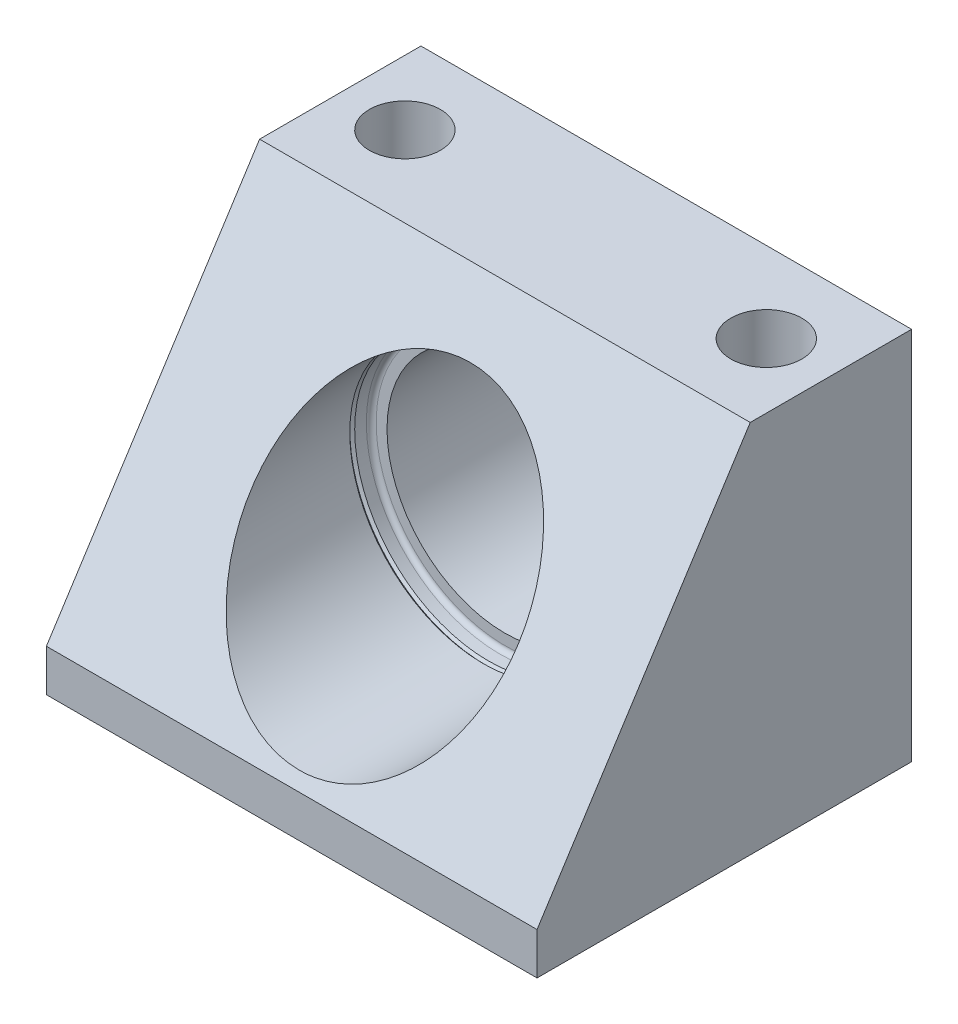
from build123d import *

# Parameters (mm, degrees)
SKETCH1_W          = 75.9968
SKETCH1_H          = 58.0136
SKETCH1_R          = 18.2625
EXTRUDE1_DEPTH     = 58.0136
CUT_EXTRUDE1_DEPTH = 76.9968
SKETCH3_R          = 20.701
CUT_EXTRUDE2_DEPTH = 33.02
FILLET1_R          = 0.762
HOLE1_D            = 10.9982
HOLE1_DEPTH        = 58.0136


with BuildPart() as part:
    # Sketch1 → Extrude1 (new body)
    with BuildSketch(Plane.XY):
        with Locations((37.9984, 29.0068)):
            Rectangle(SKETCH1_W, SKETCH1_H)
        with Locations((37.9984, 29.0068)):
            Circle(SKETCH1_R, mode=Mode.SUBTRACT)
    extrude(amount=-EXTRUDE1_DEPTH)

    # Sketch2 → Cut-Extrude1 (cut, through all)
    with BuildSketch(Plane(origin=(75.9968, 0, 0), x_dir=(0, 0, -1), z_dir=(1, 0, 0))):
        Polygon((0, 58.0136), (33.02, 58.0136), (0, 6.5024), align=None)
    extrude(amount=-CUT_EXTRUDE1_DEPTH, mode=Mode.SUBTRACT)

    # Sketch3 → Cut-Extrude2 (cut)
    with BuildSketch(Plane(origin=(0, 0, 0), x_dir=(-1, 0, 0), z_dir=(0, 0, -1))):
        with Locations(Location((-37.9984, 29.0068, 0), (0, 0, 180))):  # turned: the seam where the file's is
            Circle(SKETCH3_R)
    extrude(amount=CUT_EXTRUDE2_DEPTH, mode=Mode.SUBTRACT)

    # Fillet1
    fillet1_edges = [part.edges().sort_by_distance(p)[0] for p in [
        (17.2974, 29.0068, -33.02),
    ]]
    fillet(fillet1_edges, radius=FILLET1_R)

    # Hole1
    with Locations(Plane(origin=(0, 58.0136, 0), x_dir=(-1, 0, 0), z_dir=(0, 1, 0))):
        with Locations((-10.0076, -45.5168), (-65.9892, -45.5168)):
            Hole(HOLE1_D / 2, depth=HOLE1_DEPTH)

    # Sketch6 → Cut-Revolve1 (revolve, cut)
    with BuildSketch(Plane(origin=(0, 29.0068, 0), x_dir=(-1, 0, 0), z_dir=(0, 1, 0)), mode=Mode.PRIVATE) as cut_revolve1_sk:
        Polygon((-17.2974, -29.6926), (-17.2974, -30.4546), (-16.9164, -30.0736), align=None)
        Polygon((-19.7359, -56.8451), (-19.7359, -58.0136), (-18.5674, -58.0136), align=None)
    revolve(cut_revolve1_sk.sketch.rotate(Axis((37.9984, 29.0068, 17.508123997), (0, 0, -1)), 180), axis=Axis((37.9984, 29.0068, 17.508123997), (0, 0, -1)), mode=Mode.SUBTRACT)  # turned: the seam where the file's is


solid = part.part
